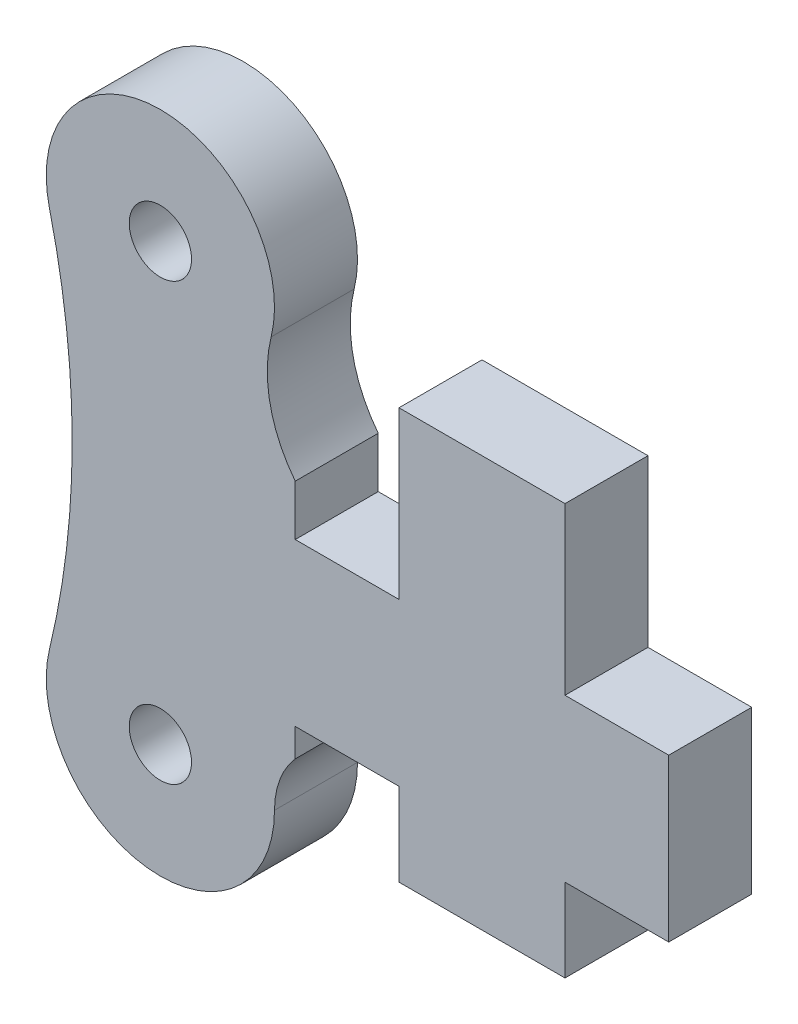
from build123d import *

# Parameters (mm, degrees)
SKETCH1_R           = 1.5
BOSS_EXTRUDE1_DEPTH = 4
SKETCH2_W           = 5
SKETCH2_H           = 5
CUT_EXTRUDE1_DEPTH  = 4


with BuildPart() as part:
    # Sketch1 → Boss-Extrude1 (new body)
    with BuildSketch(Plane.XY):
        with BuildLine():
            Line((11.5, -1.2), (11.5, -9.2))
            ThreePointArc((11.5, -9.2), (6.499964862, -6.763292795), (5.338318884, -1.323764138))
            ThreePointArc((5.338318884, -1.323764138), (0.016750191, 5.499974494), (-5.34628284, -1.291224148))
            ThreePointArc((-5.34628284, -1.291224148), (-4.25, -10.5), (-5.34628284, -19.708775852))
            ThreePointArc((-5.34628284, -19.708775852), (-0.650170894, -26.461435508), (5.5, -21))
            ThreePointArc((5.5, -21), (6.671572875, -18.171572875), (9.5, -17))
            Line((9.5, -17), (11.5, -17))
            Line((11.5, -17), (11.5, -21))
            Line((11.5, -21), (19.5, -21))
            Line((19.5, -21), (19.5, -17))
            Line((19.5, -17), (24.5, -17))
            Line((24.5, -17), (24.5, -9.2))
            Line((24.5, -9.2), (19.5, -9.2))
            Line((19.5, -9.2), (19.5, -1.2))
            Line((19.5, -1.2), (11.5, -1.2))
        make_face()
        Circle(SKETCH1_R, mode=Mode.SUBTRACT)
        with Locations((0, -21)):
            Circle(SKETCH1_R, mode=Mode.SUBTRACT)
    extrude(amount=BOSS_EXTRUDE1_DEPTH)

    # Sketch2 → Cut-Extrude1 (cut)
    with BuildSketch(Plane.XY.offset(4)):
        with Locations((9, -6.7)):
            Rectangle(SKETCH2_W, SKETCH2_H)
        with Locations((9, -19.5)):
            Rectangle(SKETCH2_W, SKETCH2_H)
    extrude(amount=-CUT_EXTRUDE1_DEPTH, mode=Mode.SUBTRACT)


solid = part.part
